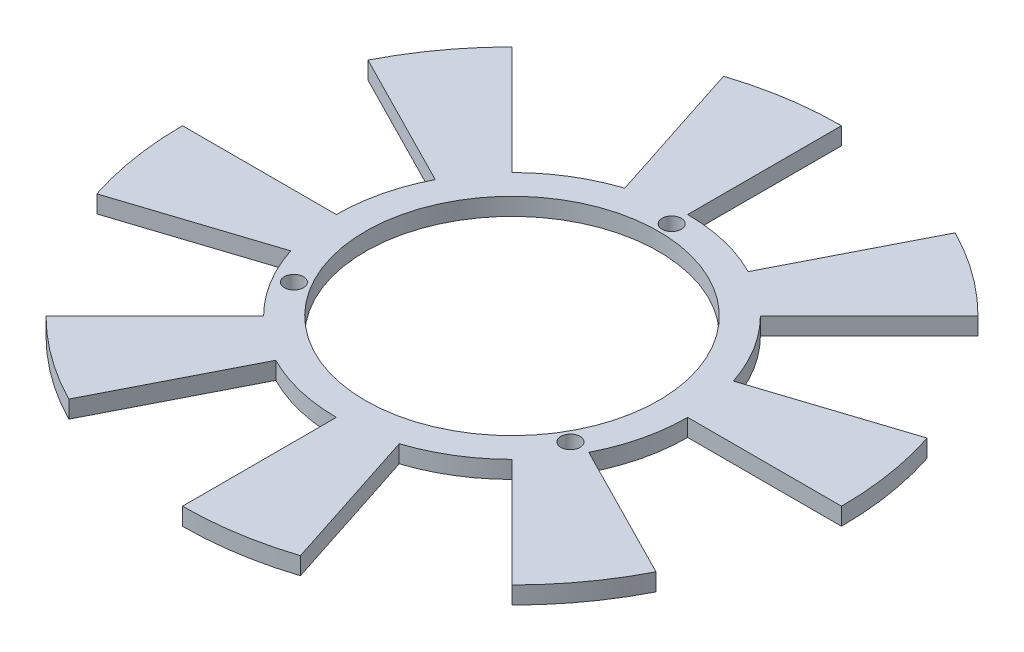
from build123d import *

# Parameters (mm, degrees)
SKETCH1_R           = 30.25
SKETCH1_R_2         = 25.25
EXTRUDE_THIN1_DEPTH = 3
SKETCH2_R           = 1.65
CUT_EXTRUDE3_DEPTH  = 10
BOSS_EXTRUDE1_DEPTH = 3


with BuildPart() as part:
    # Sketch1 → Extrude-Thin1 (new body)
    with BuildSketch(Plane(origin=(0, 0, 0), x_dir=(1, 0, 0), z_dir=(0, 1, 0))):
        Circle(SKETCH1_R)
        Circle(SKETCH1_R_2, mode=Mode.SUBTRACT)
    extrude(amount=-EXTRUDE_THIN1_DEPTH)

    # Sketch2 → Cut-Extrude3 (cut)
    with BuildSketch(Plane(origin=(0, 0, 0), x_dir=(1, 0, 0), z_dir=(0, 1, 0))):
        with Locations((0, 27.5)):
            Circle(SKETCH2_R)
        with Locations((23.815698604, -13.75)):
            Circle(SKETCH2_R)
        with Locations((-23.815698604, -13.75)):
            Circle(SKETCH2_R)
    extrude(amount=-CUT_EXTRUDE3_DEPTH, mode=Mode.SUBTRACT)

    # Sketch5 → Boss-Extrude1 (add)
    with BuildSketch(Plane.XZ.offset(3)):
        with BuildLine():
            Line((0, 56.75), (0, 30.25))
            ThreePointArc((0, 30.25), (4.732142567, 29.877572303), (9.34776408, 28.769459618))
            Line((9.34776408, 28.769459618), (17.536714431, 53.9724573))
            ThreePointArc((17.536714431, 53.9724573), (8.877655891, 56.051313329), (0, 56.75))
        make_face()
        with BuildLine():
            Line((40.128309832, 40.128309832), (21.389980131, 21.389980131))
            ThreePointArc((21.389980131, 21.389980131), (24.47276408, 17.780503882), (26.952947357, 13.733212617))
            Line((26.952947357, 13.733212617), (50.564620248, 25.76396086))
            ThreePointArc((50.564620248, 25.76396086), (45.911714431, 33.356813068), (40.128309832, 40.128309832))
        make_face()
        with BuildLine():
            Line((56.75, 0), (30.25, 0))
            ThreePointArc((30.25, 0), (29.877572303, -4.732142567), (28.769459618, -9.34776408))
            Line((28.769459618, -9.34776408), (53.9724573, -17.536714431))
            ThreePointArc((53.9724573, -17.536714431), (56.051313329, -8.877655891), (56.75, 0))
        make_face()
        with BuildLine():
            Line((40.128309832, -40.128309832), (21.389980131, -21.389980131))
            ThreePointArc((21.389980131, -21.389980131), (17.780503882, -24.47276408), (13.733212617, -26.952947357))
            Line((13.733212617, -26.952947357), (25.76396086, -50.564620248))
            ThreePointArc((25.76396086, -50.564620248), (33.356813068, -45.911714431), (40.128309832, -40.128309832))
        make_face()
        with BuildLine():
            Line((0, -56.75), (0, -30.25))
            ThreePointArc((0, -30.25), (-4.732142567, -29.877572303), (-9.34776408, -28.769459618))
            Line((-9.34776408, -28.769459618), (-17.536714431, -53.9724573))
            ThreePointArc((-17.536714431, -53.9724573), (-8.877655891, -56.051313329), (0, -56.75))
        make_face()
        with BuildLine():
            Line((-40.128309832, -40.128309832), (-21.389980131, -21.389980131))
            ThreePointArc((-21.389980131, -21.389980131), (-24.47276408, -17.780503882), (-26.952947357, -13.733212617))
            Line((-26.952947357, -13.733212617), (-50.564620248, -25.76396086))
            ThreePointArc((-50.564620248, -25.76396086), (-45.911714431, -33.356813068), (-40.128309832, -40.128309832))
        make_face()
        with BuildLine():
            Line((-56.75, 0), (-30.25, 0))
            ThreePointArc((-30.25, 0), (-29.877572303, 4.732142567), (-28.769459618, 9.34776408))
            Line((-28.769459618, 9.34776408), (-53.9724573, 17.536714431))
            ThreePointArc((-53.9724573, 17.536714431), (-56.051313329, 8.877655891), (-56.75, 0))
        make_face()
        with BuildLine():
            Line((-40.128309832, 40.128309832), (-21.389980131, 21.389980131))
            ThreePointArc((-21.389980131, 21.389980131), (-17.780503882, 24.47276408), (-13.733212617, 26.952947357))
            Line((-13.733212617, 26.952947357), (-25.76396086, 50.564620248))
            ThreePointArc((-25.76396086, 50.564620248), (-33.356813068, 45.911714431), (-40.128309832, 40.128309832))
        make_face()
    extrude(amount=-BOSS_EXTRUDE1_DEPTH)


solid = part.part
